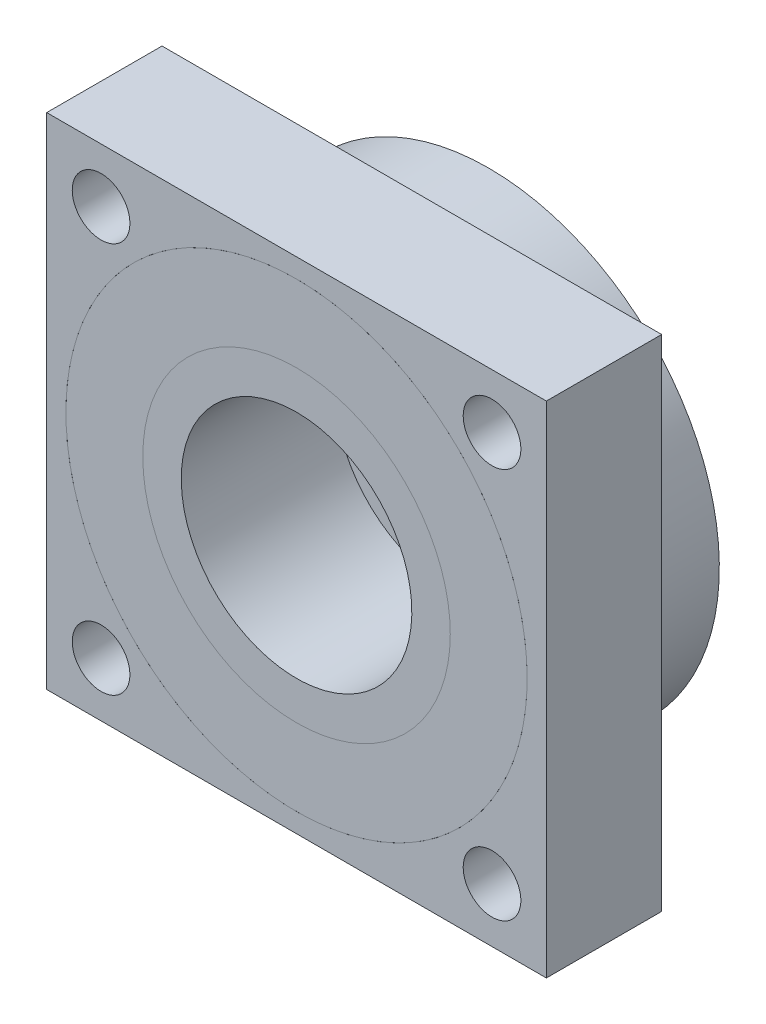
from build123d import *

# Parameters (mm, degrees)
SKETCH1_W           = 12.7
SKETCH1_H           = 5.08
SKETCH1_4_W         = 12.7
SKETCH1_4_H         = 2.54
SKETCH3_W           = 33.02
SKETCH3_H           = 33.02
SKETCH3_R           = 15.24
BOSS_EXTRUDE1_DEPTH = 7.62
SKETCH4_R           = 1.905
CUT_EXTRUDE2_DEPTH  = 8.62
BOSS_EXTRUDE3_START = -12.7
SKETCH5_R           = 10.16
BOSS_EXTRUDE3_DEPTH = 2.54


with BuildPart() as part:
    # Sketch1 → Revolve2 (revolve)
    with BuildSketch(Plane(origin=(0, 0, 0), x_dir=(0, 0, -1), z_dir=(1, 0, 0))):
        with Locations((6.35, 12.7)):
            Rectangle(SKETCH1_W, SKETCH1_H)
    revolve(axis=Axis((0, 0, -12.7), (0, 0, 1)))


with BuildPart() as body_2:
    # Sketch1_4 → Revolve3 (revolve)
    with BuildSketch(Plane(origin=(0, 0, 0), x_dir=(0, 0, -1), z_dir=(1, 0, 0))):
        with Locations((6.35, 8.89)):
            Rectangle(SKETCH1_4_W, SKETCH1_4_H)
    revolve(axis=Axis((0, 0, -12.7), (0, 0, 1)))


with BuildPart() as body_3:
    # Sketch3 → Boss-Extrude1 (new body)
    with BuildSketch(Plane.XY):
        Rectangle(SKETCH3_W, SKETCH3_H)
        Circle(SKETCH3_R, mode=Mode.SUBTRACT)
    extrude(amount=-BOSS_EXTRUDE1_DEPTH)

    # Sketch4 → Cut-Extrude2 (cut, through all)
    with BuildSketch(Plane(origin=(0, 0, -7.62), x_dir=(-1, 0, 0), z_dir=(0, 0, -1))):
        with Locations((-12.917897552, 12.917897552)):
            Circle(SKETCH4_R)
        with Locations((12.917897552, 12.917897552)):
            Circle(SKETCH4_R)
        with Locations((12.917897552, -12.917897552)):
            Circle(SKETCH4_R)
        with Locations((-12.917897552, -12.917897552)):
            Circle(SKETCH4_R)
    extrude(amount=-CUT_EXTRUDE2_DEPTH, mode=Mode.SUBTRACT)


with BuildPart() as body_4:
    # Sketch5 → Boss-Extrude3 (new body)
    with BuildSketch(Plane.XY.offset(BOSS_EXTRUDE3_START)):
        Circle(SKETCH5_R)
    extrude(amount=BOSS_EXTRUDE3_DEPTH)


with BuildPart() as body_2_1:
    add(body_2.part)

    # Combine1: union body 4
    add(body_4.part)


solid = Compound([part.part, body_3.part, body_2_1.part])
